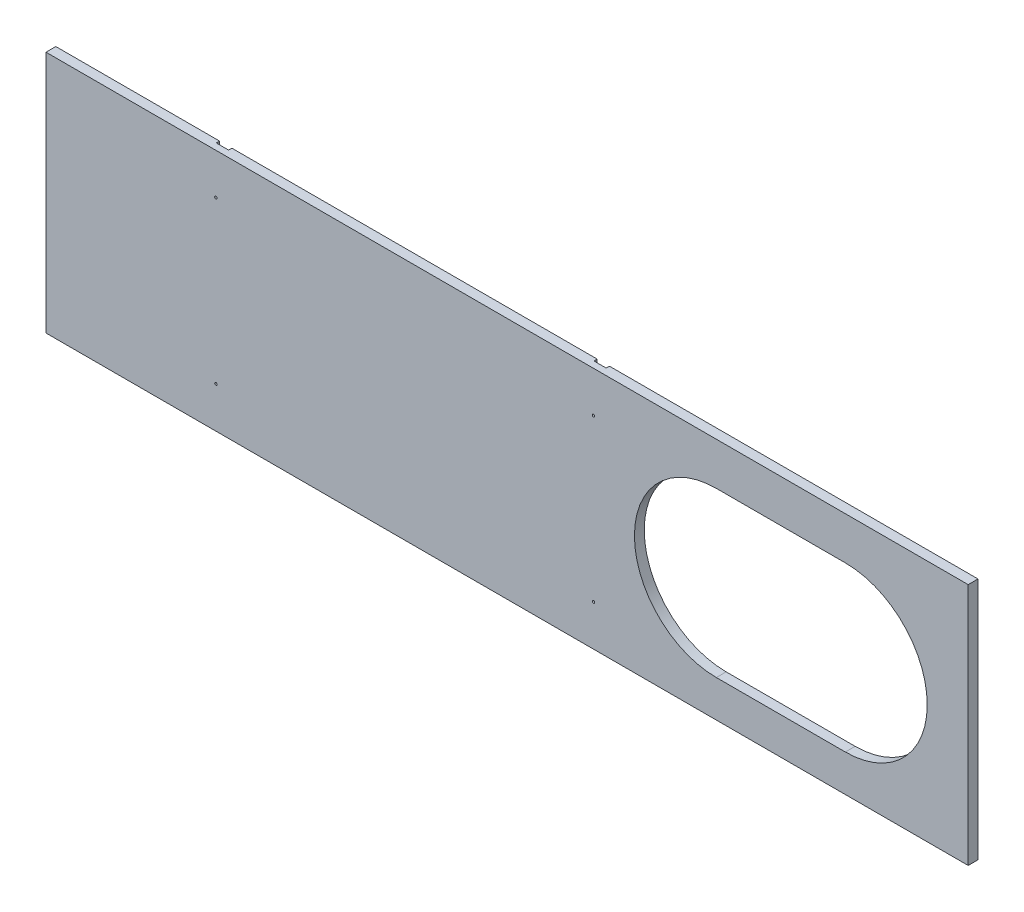
from build123d import *

# Parameters (mm, degrees)
ESQUISSE1_W             = 1126
ESQUISSE1_H             = 297
ESQUISSE1_R             = 1.5
BOSS_EXTRU_1_DEPTH      = 12
ESQUISSE2_W             = 15
ESQUISSE2_H             = 678.559774038
ESQUISSE2_H_2           = 656.681006804
ENL_V_MAT_EXTRU_1_DEPTH = 4


with BuildPart() as part:
    # Esquisse1 → Boss.-Extru.1 (new body)
    with BuildSketch(Plane.XY):
        Rectangle(ESQUISSE1_W, ESQUISSE1_H)
        with Locations((105.5, 98.5)):
            Circle(ESQUISSE1_R, mode=Mode.SUBTRACT)
        with Locations((105.5, -98.5)):
            Circle(ESQUISSE1_R, mode=Mode.SUBTRACT)
        with Locations((-355.5, 98.5)):
            Circle(ESQUISSE1_R, mode=Mode.SUBTRACT)
        with Locations((-355.5, -98.5)):
            Circle(ESQUISSE1_R, mode=Mode.SUBTRACT)
        with BuildLine():
            Line((255.5, 96.5), (413, 96.5))
            ThreePointArc((413, 96.5), (513, -3.5), (413, -103.5))
            Line((413, -103.5), (255.5, -103.5))
            ThreePointArc((255.5, -103.5), (155.5, -3.5), (255.5, 96.5))
        make_face(mode=Mode.SUBTRACT)
    extrude(amount=BOSS_EXTRU_1_DEPTH)

    # Esquisse2 → Enlèv. mat.-Extru.1 (cut)
    with BuildSketch(Plane(origin=(0, 0, 0), x_dir=(-1, 0, 0), z_dir=(0, 0, -1))):
        with Locations((-105.5, 98.5)):
            Rectangle(ESQUISSE2_W, ESQUISSE2_H)
        with Locations((355.5, 98.5)):
            Rectangle(ESQUISSE2_W, ESQUISSE2_H_2)
    extrude(amount=-ENL_V_MAT_EXTRU_1_DEPTH, mode=Mode.SUBTRACT)


solid = part.part
